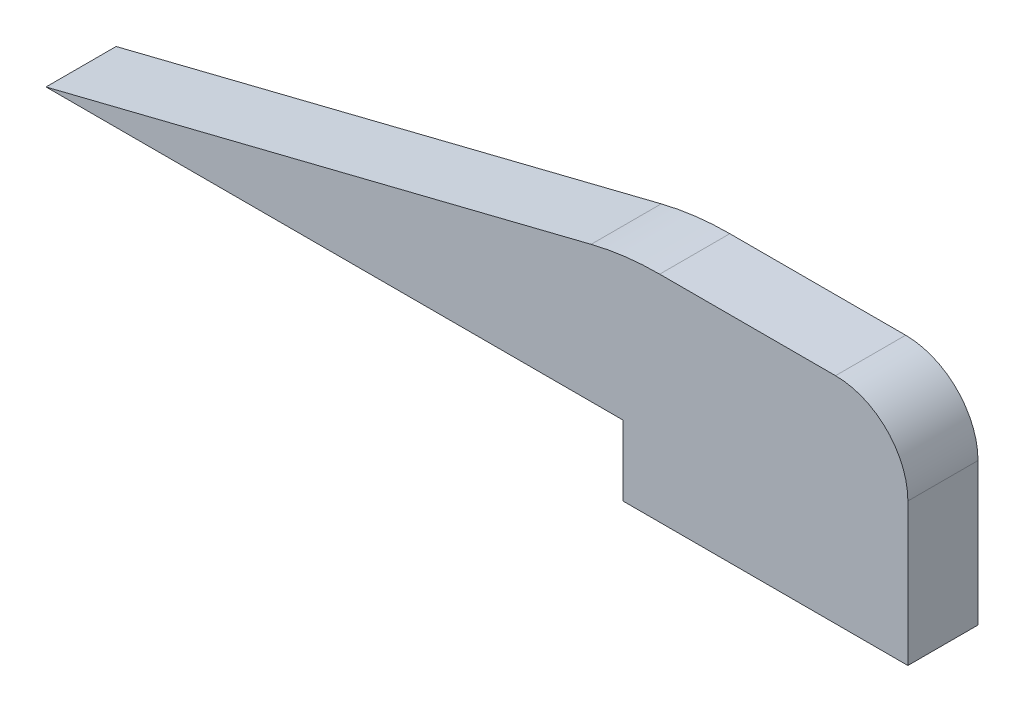
from build123d import *

# Parameters (mm, degrees)
BOSS_EXTRUDE1_DEPTH = 3.175


with BuildPart() as part:
    # Sketch1 → Boss-Extrude1 (new body)
    with BuildSketch(Plane.XY):
        with BuildLine():
            Line((38.2016, 3.175), (38.2016, -3.2766))
            Line((38.2016, -3.2766), (25.2984, -3.2766))
            Line((25.2984, -3.2766), (25.2984, -0.1016))
            Line((25.2984, -0.1016), (-0.825307532, -0.1016))
            Line((-0.825307532, -0.1016), (23.858597388, 6.06937623))
            ThreePointArc((23.858597388, 6.06937623), (25.399300177, 6.355684738), (26.963441445, 6.4516))
            Line((26.963441445, 6.4516), (34.925, 6.4516))
            ThreePointArc((34.925, 6.4516), (37.241906079, 5.491906079), (38.2016, 3.175))
        make_face()
    extrude(amount=BOSS_EXTRUDE1_DEPTH)


solid = part.part
